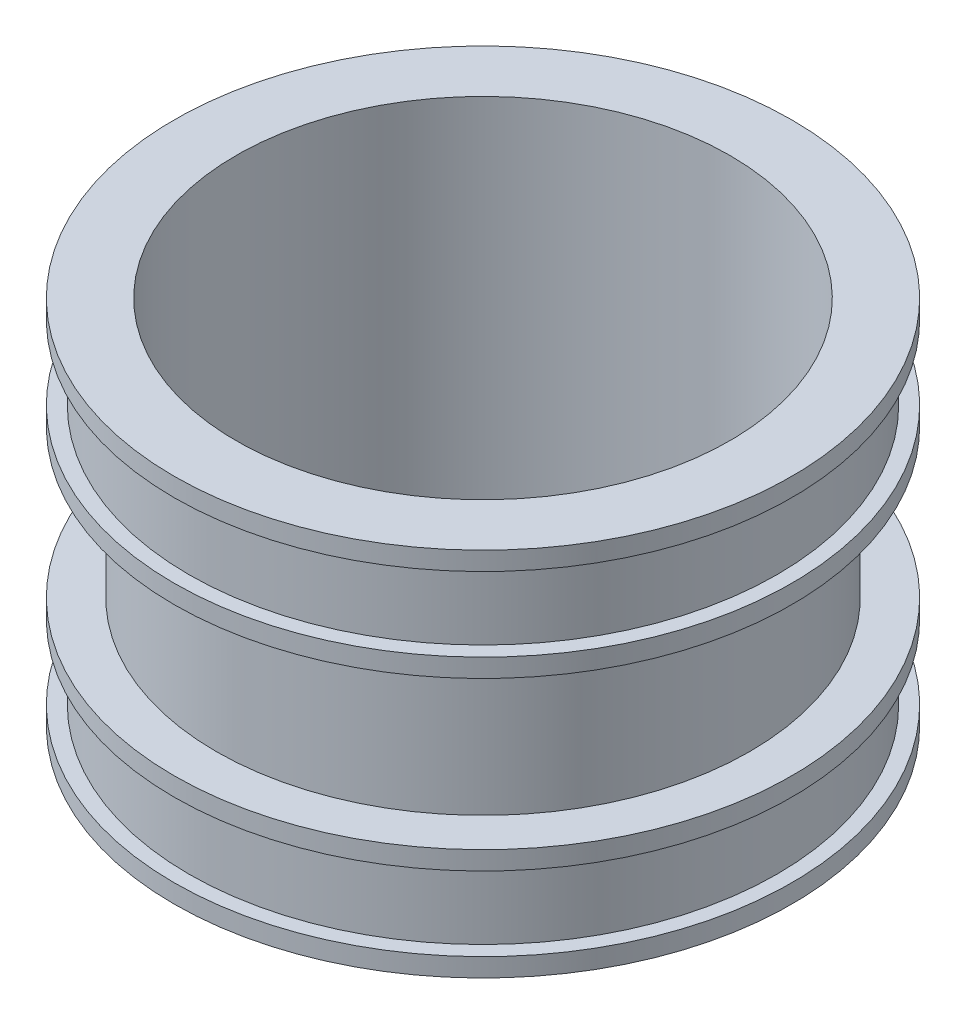
from build123d import *


with BuildPart() as part:
    # Esboço1 → Revolução1 (revolve)
    with BuildSketch(Plane.XY):
        Polygon((100, 150), (125, 150), (125, 142.5), (119, 142.5), (119, 112.5), (125, 112.5), (125, 105), (108, 105), (108, 45), (125, 45), (125, 37.5), (119, 37.5), (119, 7.5), (125, 7.5), (125, 0), (100, 0), align=None)
    revolve(axis=Axis((0, 0, 0), (0, 1, 0)))


solid = part.part
